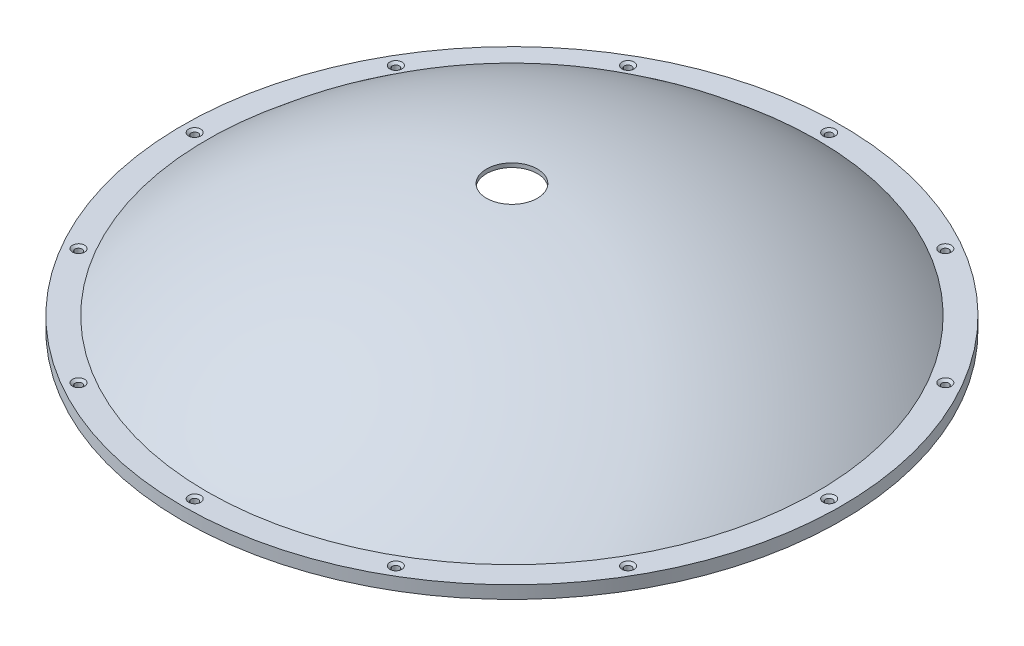
from build123d import *

# Parameters (mm, degrees)
CSK_FOR_0_FLAT_HEAD_MACHINE_SCREW_100_D           = 1.778
CSK_FOR_0_FLAT_HEAD_MACHINE_SCREW_100_CSINK_D     = 3.0226
CSK_FOR_0_FLAT_HEAD_MACHINE_SCREW_100_CSINK_ANGLE = 100
CIRPATTERN1_COUNT                                 = 12


with BuildPart() as part:
    # Sketch1 → Revolve1 (revolve)
    with BuildSketch(Plane.XY):
        with BuildLine():
            Line((-82.3595, 0), (-76.2, 0))
            ThreePointArc((-76.2, 0), (-75.836445405, 1.67032541), (-74.811557259, 3.038449384))
            ThreePointArc((-74.811557259, 3.038449384), (-42.880368086, 22.574179563), (-6.35, 30.745948226))
            Line((-6.35, 30.745948226), (-6.35, 31.763505888))
            ThreePointArc((-6.35, 31.763505888), (-43.680101788, 23.345613205), (-76.2, 3.175))
            Line((-76.2, 3.175), (-82.3595, 3.175))
            Line((-82.3595, 3.175), (-82.3595, 0))
        make_face()
    revolve(axis=Axis((0, 55, 0), (0, -1, 0)))

    # CSK for #0 Flat Head Machine Screw (100)1 (through all)
    with Locations(Plane(origin=(0, 3.175, 0), x_dir=(1, 0, 0), z_dir=(0, 1, 0))):
        with Locations((-79.27975, 0)):
            csk_for_0_flat_head_machine_screw_100 = CounterSinkHole(CSK_FOR_0_FLAT_HEAD_MACHINE_SCREW_100_D / 2, CSK_FOR_0_FLAT_HEAD_MACHINE_SCREW_100_CSINK_D / 2, counter_sink_angle=CSK_FOR_0_FLAT_HEAD_MACHINE_SCREW_100_CSINK_ANGLE)

    # CirPattern1: CSK for #0 Flat Head Machine Screw (100)1 ×12 about axis
    cirpattern1_axis = Axis((0, 0, 0), (0, 1, 0))
    for i in range(1, CIRPATTERN1_COUNT):
        add(csk_for_0_flat_head_machine_screw_100.rotate(cirpattern1_axis, i * 360 / CIRPATTERN1_COUNT), mode=Mode.SUBTRACT)


solid = part.part
